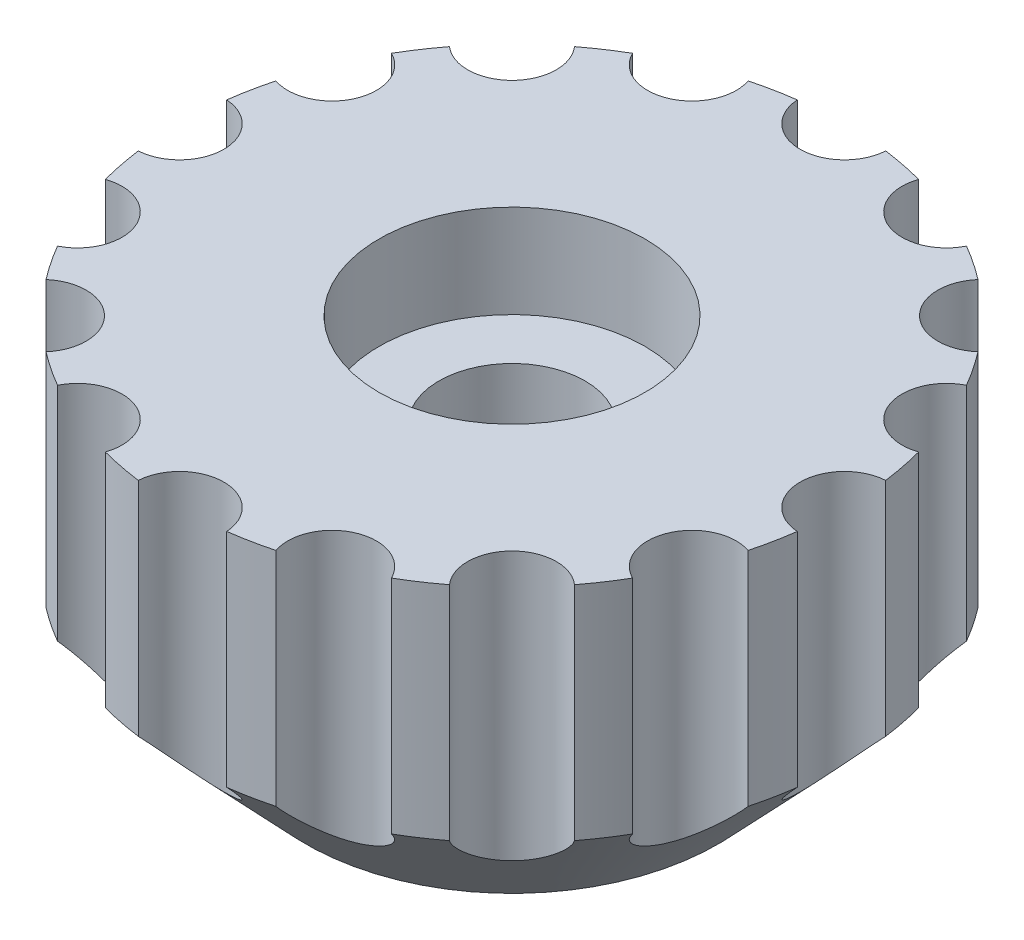
from build123d import *

# Parameters (mm, degrees)
CORTE_EXTRUS_O1_DEPTH = 3
ESBO_O4_R             = 1
CORTE_EXTRUS_O2_DEPTH = 10


with BuildPart() as part:
    # Esboço1 → Revolução1 (revolve)
    with BuildSketch(Plane.XY):
        Polygon((-3, 8), (-7.5, 8), (-7.5, 3), (-4.65, 0), (-1.65, 0), (-1.65, 5.9), (-3, 5.9), align=None)
    revolve(axis=Axis((0, 0, 0), (0, 1, 0)))

    # Esboço3 → Corte-extrusão1 (cut)
    with BuildSketch(Plane.XZ):
        Polygon((3.175426481, 0), (1.58771324, 2.75), (-1.58771324, 2.75), (-3.175426481, 0), (-1.58771324, -2.75), (1.58771324, -2.75), align=None)
    extrude(amount=-CORTE_EXTRUS_O1_DEPTH, mode=Mode.SUBTRACT)

    # Esboço4 → Corte-extrusão2 (cut)
    with BuildSketch(Plane(origin=(0, 8, 0), x_dir=(1, 0, 0), z_dir=(0, 1, 0))):
        with Locations((0, 7.5)):
            Circle(ESBO_O4_R)
        with Locations((2.870125743, 6.929096494)):
            Circle(ESBO_O4_R)
        with Locations((5.303300859, 5.303300859)):
            Circle(ESBO_O4_R)
        with Locations((6.929096494, 2.870125743)):
            Circle(ESBO_O4_R)
        with Locations((7.5, 0)):
            Circle(ESBO_O4_R)
        with Locations((6.929096494, -2.870125743)):
            Circle(ESBO_O4_R)
        with Locations((5.303300859, -5.303300859)):
            Circle(ESBO_O4_R)
        with Locations((2.870125743, -6.929096494)):
            Circle(ESBO_O4_R)
        with Locations((0, -7.5)):
            Circle(ESBO_O4_R)
        with Locations((-2.870125743, -6.929096494)):
            Circle(ESBO_O4_R)
        with Locations((-5.303300859, -5.303300859)):
            Circle(ESBO_O4_R)
        with Locations((-6.929096494, -2.870125743)):
            Circle(ESBO_O4_R)
        with Locations((-7.5, 0)):
            Circle(ESBO_O4_R)
        with Locations((-6.929096494, 2.870125743)):
            Circle(ESBO_O4_R)
        with Locations((-5.303300859, 5.303300859)):
            Circle(ESBO_O4_R)
        with Locations((-2.870125743, 6.929096494)):
            Circle(ESBO_O4_R)
    extrude(amount=-CORTE_EXTRUS_O2_DEPTH, mode=Mode.SUBTRACT)


solid = part.part
